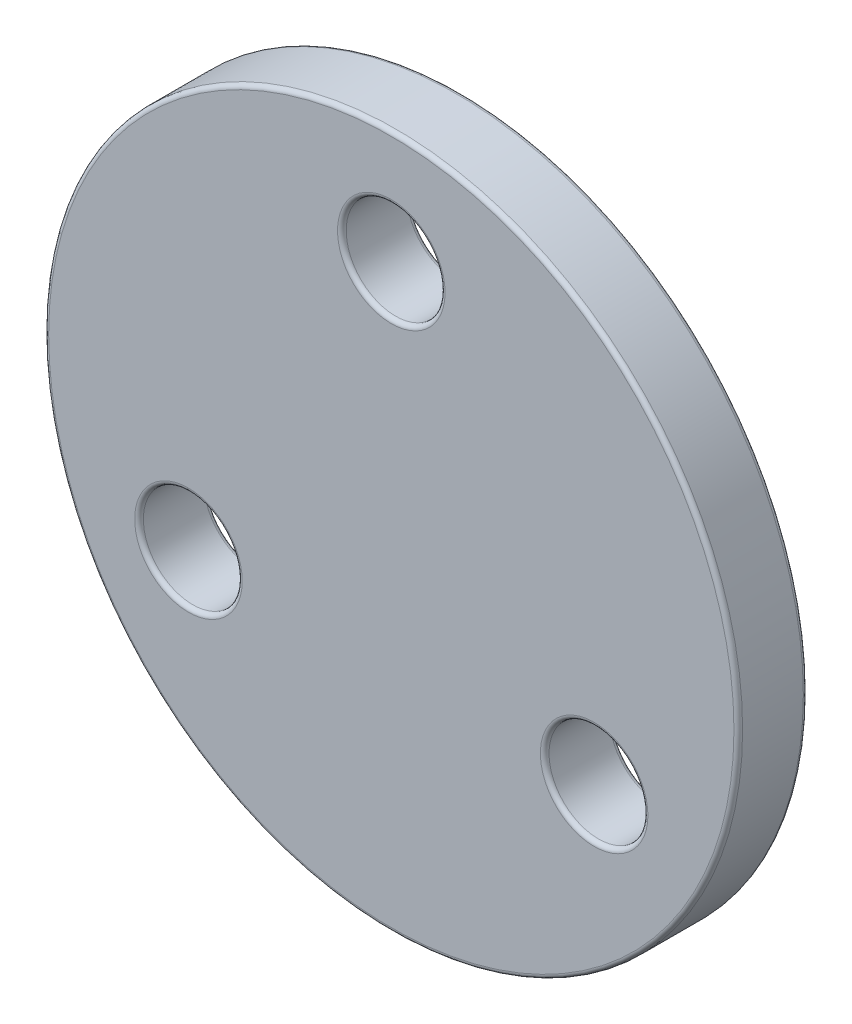
from build123d import *

# Parameters (mm, degrees)
CROQUIS1_R              = 20
SALIENTE_EXTRUIR1_DEPTH = 4
CROQUIS2_R              = 2.85
CORTAR_EXTRUIR2_DEPTH   = 4
REDONDEO1_R             = 0.25


with BuildPart() as part:
    # Croquis1 → Saliente-Extruir1 (new body)
    with BuildSketch(Plane.XY):
        Circle(CROQUIS1_R)
    extrude(amount=SALIENTE_EXTRUIR1_DEPTH)

    # Croquis2 → Cortar-Extruir2 (cut)
    with BuildSketch(Plane.XY):
        with Locations((0, 13.5)):
            Circle(CROQUIS2_R)
        with Locations((11.691342951, -6.75)):
            Circle(CROQUIS2_R)
        with Locations((-11.691342951, -6.75)):
            Circle(CROQUIS2_R)
    extrude(amount=CORTAR_EXTRUIR2_DEPTH, mode=Mode.SUBTRACT)

    # Redondeo1
    redondeo1_edges = [part.edges().sort_by_distance(p)[0] for p in [
        (-14.541342951, -6.75, 0),
        (-14.541342951, -6.75, 4),
        (8.841342951, -6.75, 0),
        (8.841342951, -6.75, 4),
        (-20, 0, 0),
        (-20, 0, 4),
        (-2.85, 13.5, 0),
        (-2.85, 13.5, 4),
    ]]
    fillet(redondeo1_edges, radius=REDONDEO1_R)


solid = part.part
